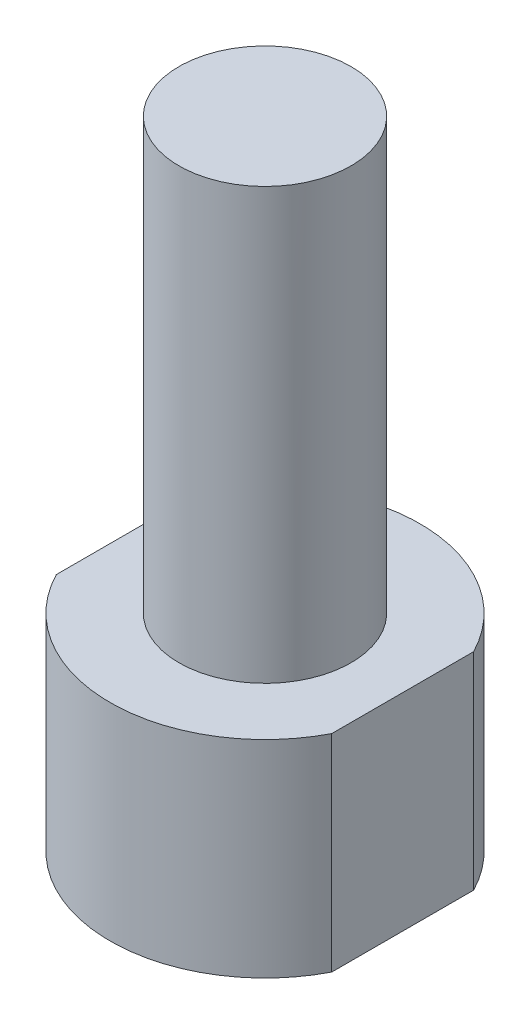
from build123d import *

# Parameters (mm, degrees)
EXTRUDE_1_DEPTH = 12
SKETCH_2_W      = 5
SKETCH_2_H      = 25


with BuildPart() as part:
    # 草图1 → 凸台-拉伸1 (new body)
    with BuildSketch(Plane(origin=(0, 12, 0), x_dir=(1, 0, 0), z_dir=(0, 1, 0))):
        with BuildLine():
            Line((-8, 4.123105626), (-8, -4.123105626))
            ThreePointArc((-8, -4.123105626), (0, -9), (8, -4.123105626))
            Line((8, -4.123105626), (8, 4.123105626))
            ThreePointArc((8, 4.123105626), (0, 9), (-8, 4.123105626))
        make_face()
    extrude(amount=-EXTRUDE_1_DEPTH)

    # 草图2 → 旋转1 (revolve)
    with BuildSketch(Plane.XY):
        with Locations((2.5, 24.5)):
            Rectangle(SKETCH_2_W, SKETCH_2_H)
    revolve(axis=Axis((0, 37, 0), (0, -1, 0)))


solid = part.part
